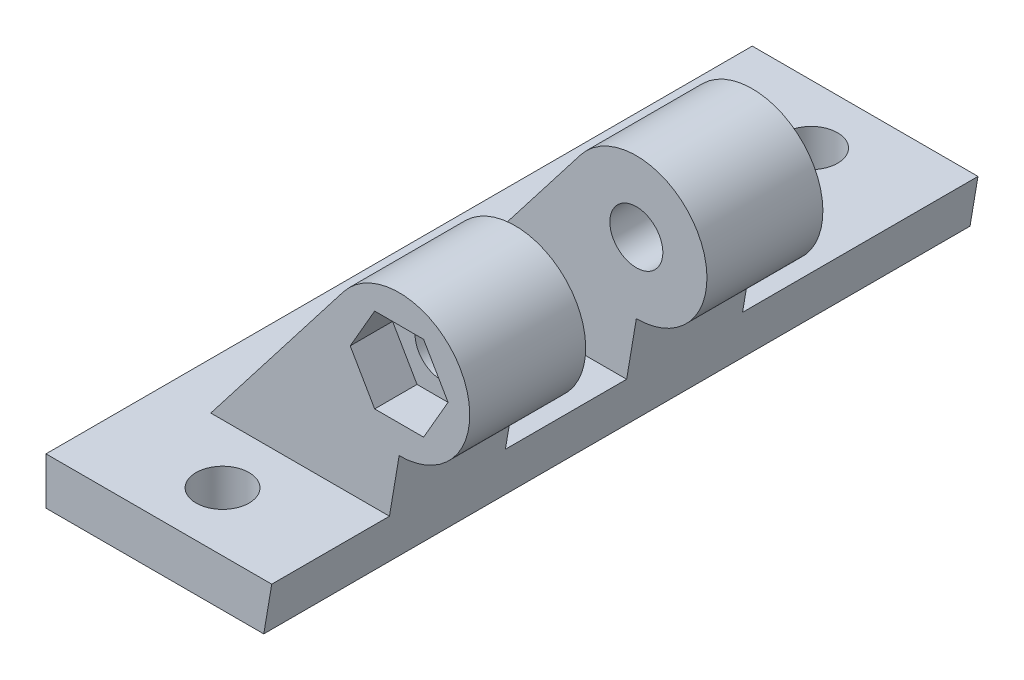
from build123d import *

# Parameters (mm, degrees)
SKETCH1_W           = 20
SKETCH1_H           = 60
SKETCH1_R           = 2.25
BOSS_EXTRUDE1_DEPTH = 5
SKETCH2_R           = 2.25
BOSS_EXTRUDE2_DEPTH = 9.85
SKETCH3_R           = 2.25
BOSS_EXTRUDE3_DEPTH = 9.85
SKETCH4_W           = 33.827008901
SKETCH4_H           = 72.568076527
CUT_EXTRUDE1_DEPTH  = 1
CUT_EXTRUDE2_DEPTH  = 61
CUT_EXTRUDE3_DEPTH  = 3.6


with BuildPart() as part:
    # Sketch1 → Boss-Extrude1 (new body)
    with BuildSketch(Plane(origin=(0, 0, 0), x_dir=(1, 0, 0), z_dir=(0, 1, 0))):
        Rectangle(SKETCH1_W, SKETCH1_H)
        with Locations((0, 25)):
            Circle(SKETCH1_R, mode=Mode.SUBTRACT)
        with Locations((0, -25)):
            Circle(SKETCH1_R, mode=Mode.SUBTRACT)
    extrude(amount=BOSS_EXTRUDE1_DEPTH)

    # Sketch2 → Boss-Extrude2 (add)
    with BuildSketch(Plane.XY.offset(20)):
        with BuildLine():
            Line((10, 9.86530346), (10, 5))
            Line((10, 5), (-6, 5))
            Line((-6, 5), (5.255684086, 19.53837663))
            ThreePointArc((5.255684086, 19.53837663), (15.386948998, 18.507420129), (10, 9.86530346))
        make_face()
        with Locations((10, 15.86530346)):
            Circle(SKETCH2_R, mode=Mode.SUBTRACT)
    extrude(amount=-BOSS_EXTRUDE2_DEPTH)

    # Sketch3 → Boss-Extrude3 (add)
    with BuildSketch(Plane(origin=(0, 0, -10), x_dir=(-1, 0, 0), z_dir=(0, 0, -1))):
        with BuildLine():
            Line((-10, 9.86530346), (-10, 5))
            Line((-10, 5), (6, 5))
            Line((6, 5), (-5.293415142, 19.586601483))
            ThreePointArc((-5.293415142, 19.586601483), (-15.40036055, 18.479898253), (-10, 9.86530346))
        make_face()
        with Locations((-10, 15.86530346)):
            Circle(SKETCH3_R, mode=Mode.SUBTRACT)
    extrude(amount=-BOSS_EXTRUDE3_DEPTH)

    # Sketch4 → Cut-Extrude1 (cut)
    with BuildSketch(Plane.XZ):
        with Locations((1.488581003, -1.778467764)):
            Rectangle(SKETCH4_W, SKETCH4_H)
    extrude(amount=-CUT_EXTRUDE1_DEPTH, mode=Mode.SUBTRACT)

    # Sketch5 → Cut-Extrude2 (cut, through all)
    with BuildSketch(Plane(origin=(0, 0, -30), x_dir=(-1, 0, 0), z_dir=(0, 0, -1))):
        Polygon((-10, 9.86530346), (-10, 1), (-8.5, 1), align=None)
    extrude(amount=-CUT_EXTRUDE2_DEPTH, mode=Mode.SUBTRACT)

    # Sketch6 → Cut-Extrude3 (cut)
    with BuildSketch(Plane.XY.offset(20)):
        Polygon((12.078460969, 12.26530346), (14.156921938, 15.86530346), (12.078460969, 19.46530346), (7.921539031, 19.46530346), (5.843078062, 15.86530346), (7.921539031, 12.26530346), align=None)
    extrude(amount=-CUT_EXTRUDE3_DEPTH, mode=Mode.SUBTRACT)


solid = part.part
